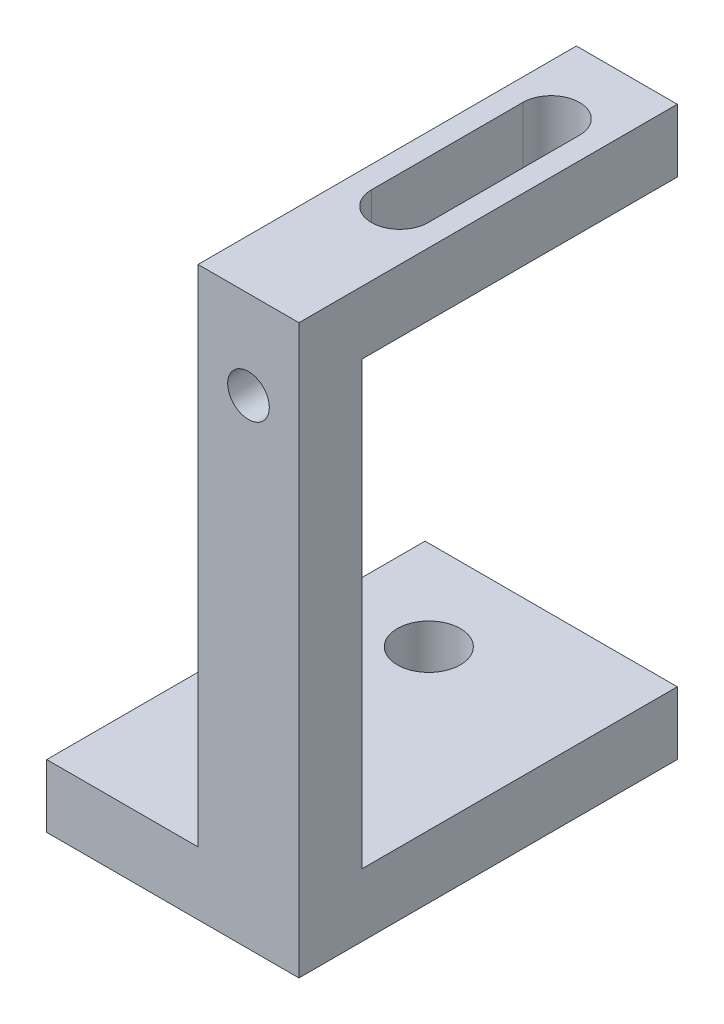
from build123d import *

# Parameters (mm, degrees)
SKETCH_1_W             = 8
SKETCH_1_H             = 20
EXTRUDE_1_DEPTH        = 10
SKETCH_2_W             = 5
SKETCH_2_H             = 15
CUT_EXTRUDE_1_DEPTH    = 10
SKETCH_3_W             = 8
SKETCH_3_H             = 5
EXTRUDE_2_DEPTH        = 5
SKETCH_4_W             = 8
SKETCH_4_H             = 5
EXTRUDE_3_DEPTH        = 20
SKETCH_5_W             = 20
SKETCH_5_H             = 30
EXTRUDE_4_DEPTH        = 5
SKETCH_6_R             = 2.5
CUT_EXTRUDE_2_DEPTH    = 5
SKETCH_7_W             = 8
SKETCH_7_H             = 5
EXTRUDE_5_DEPTH        = 15
CUT_EXTRUDE_3_DEPTH    = 10
HOLE_WIZARD_M4_1_D     = 3.3
HOLE_WIZARD_M4_1_DEPTH = 10.1
HOLE_WIZARD_M4_1_TIP   = 0.991420021


with BuildPart() as part:
    # 草图1 → 凸台-拉伸1 (new body)
    with BuildSketch(Plane.XY):
        with Locations((4, 10)):
            Rectangle(SKETCH_1_W, SKETCH_1_H)
    extrude(amount=EXTRUDE_1_DEPTH)

    # 草图2 → 切除-拉伸1 (cut)
    with BuildSketch(Plane.ZY):
        with Locations((2.5, 7.5)):
            Rectangle(SKETCH_2_W, SKETCH_2_H)
    extrude(amount=-CUT_EXTRUDE_1_DEPTH, mode=Mode.SUBTRACT)

    # 草图3 → 凸台-拉伸2 (add)
    with BuildSketch(Plane(origin=(0, 0, 0), x_dir=(-1, 0, 0), z_dir=(0, 0, -1))):
        with Locations((-4, 17.5)):
            Rectangle(SKETCH_3_W, SKETCH_3_H)
    extrude(amount=EXTRUDE_2_DEPTH)

    # 草图4 → 凸台-拉伸3 (add)
    with BuildSketch(Plane.XZ):
        with Locations((4, 7.5)):
            Rectangle(SKETCH_4_W, SKETCH_4_H)
    extrude(amount=EXTRUDE_3_DEPTH)

    # 草图5 → 凸台-拉伸4 (add)
    with BuildSketch(Plane.XZ.offset(20)):
        with Locations((-2, -5)):
            Rectangle(SKETCH_5_W, SKETCH_5_H)
    extrude(amount=EXTRUDE_4_DEPTH)

    # 草图6 → 切除-拉伸2 (cut)
    with BuildSketch(Plane(origin=(0, -20, 0), x_dir=(1, 0, 0), z_dir=(0, 1, 0))):
        with Locations((-4.6, 12.897897411)):
            Circle(SKETCH_6_R)
    extrude(amount=-CUT_EXTRUDE_2_DEPTH, mode=Mode.SUBTRACT)

    # 草图7 → 凸台-拉伸5 (add)
    with BuildSketch(Plane(origin=(0, 0, -5), x_dir=(-1, 0, 0), z_dir=(0, 0, -1))):
        with Locations((-4, 17.5)):
            Rectangle(SKETCH_7_W, SKETCH_7_H)
    extrude(amount=EXTRUDE_5_DEPTH)

    # 草图8 → 切除-拉伸3 (cut)
    with BuildSketch(Plane(origin=(0, 20, 0), x_dir=(1, 0, 0), z_dir=(0, 1, 0))):
        with BuildLine():
            Line((6.25, 14), (6.25, 2))
            ThreePointArc((6.25, 2), (4, -0.25), (1.75, 2))
            Line((1.75, 2), (1.75, 14))
            ThreePointArc((1.75, 14), (4, 16.25), (6.25, 14))
        make_face()
    extrude(amount=-CUT_EXTRUDE_3_DEPTH, mode=Mode.SUBTRACT)

    # M4 螺纹孔1
    with Locations(Plane.XY.offset(10)):
        with Locations((4, 13)):
            Hole(HOLE_WIZARD_M4_1_D / 2, depth=HOLE_WIZARD_M4_1_DEPTH)
            with Locations((0, 0, -(HOLE_WIZARD_M4_1_DEPTH + HOLE_WIZARD_M4_1_TIP / 2))):  # 118° drill point
                Cone(0, HOLE_WIZARD_M4_1_D / 2, HOLE_WIZARD_M4_1_TIP, mode=Mode.SUBTRACT)


solid = part.part
